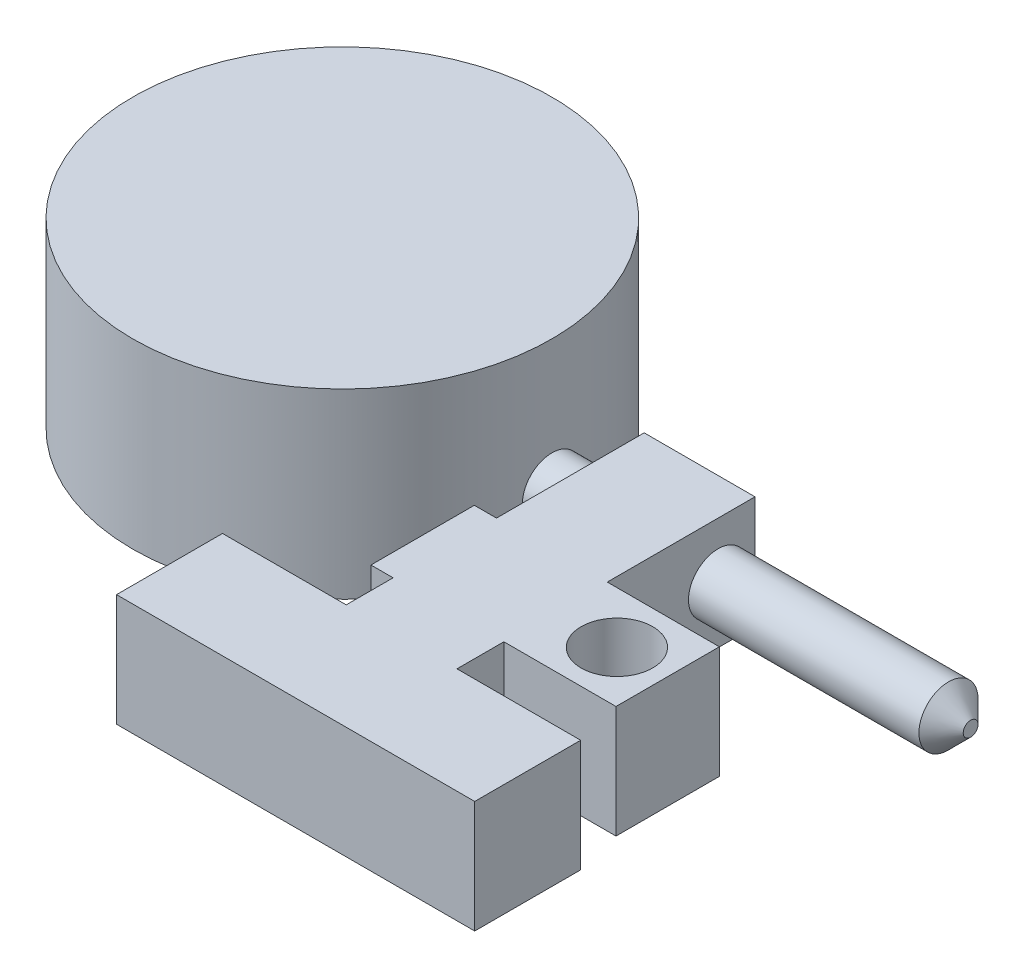
from build123d import *

# Parameters (mm, degrees)
SKETCH1_R           = 28.375
BOSS_EXTRUDE1_DEPTH = 24.66
SKETCH3_R           = 4
BOSS_EXTRUDE2_DEPTH = 56.7
CHAMFER1_SIZE       = 3
BOSS_EXTRUDE3_DEPTH = 7.6
SKETCH6_R           = 4.85
CUT_EXTRUDE1_DEPTH  = 15.2


with BuildPart() as part:
    # Sketch1 → Boss-Extrude1 (new body)
    with BuildSketch(Plane(origin=(0, 0, 0), x_dir=(1, 0, 0), z_dir=(0, 1, 0))):
        Circle(SKETCH1_R)
    extrude(amount=BOSS_EXTRUDE1_DEPTH)


with BuildPart() as body_2:
    # Sketch3 → Boss-Extrude2 (new body)
    with BuildSketch(Plane(origin=(28.375, 0, 0), x_dir=(0, 0, -1), z_dir=(1, 0, 0))):
        with Locations((0, 7.3)):
            Circle(SKETCH3_R)
    extrude(amount=BOSS_EXTRUDE2_DEPTH)

    # Chamfer1
    chamfer1_edges = [body_2.edges().sort_by_distance(p)[0] for p in [
        (85.075, 7.3, 4),
    ]]
    chamfer(chamfer1_edges, length=CHAMFER1_SIZE)

    # Sketch5 → Boss-Extrude3 (add, symmetric)
    with BuildSketch(Plane(origin=(0, 7.3, 0), x_dir=(1, 0, 0), z_dir=(0, 1, 0))):
        Polygon((35.875, 5), (35.875, -15), (32.875, -15), (32.875, -29), (35.875, -29), (35.875, -35.35), (19.125, -35.35), (19.125, -49.7), (67.625, -49.7), (67.625, -35.35), (50.875, -35.35), (50.875, -29), (66.055, -29), (66.055, -15), (50.875, -15), (50.875, 5), align=None)
    extrude(amount=BOSS_EXTRUDE3_DEPTH, both=True)

    # Sketch6 → Cut-Extrude1 (cut)
    with BuildSketch(Plane(origin=(0, 14.9, 0), x_dir=(1, 0, 0), z_dir=(0, 1, 0))):
        with Locations((59.18, -22)):
            Circle(SKETCH6_R)
    extrude(amount=-CUT_EXTRUDE1_DEPTH, mode=Mode.SUBTRACT)


solid = Compound([part.part, body_2.part])
